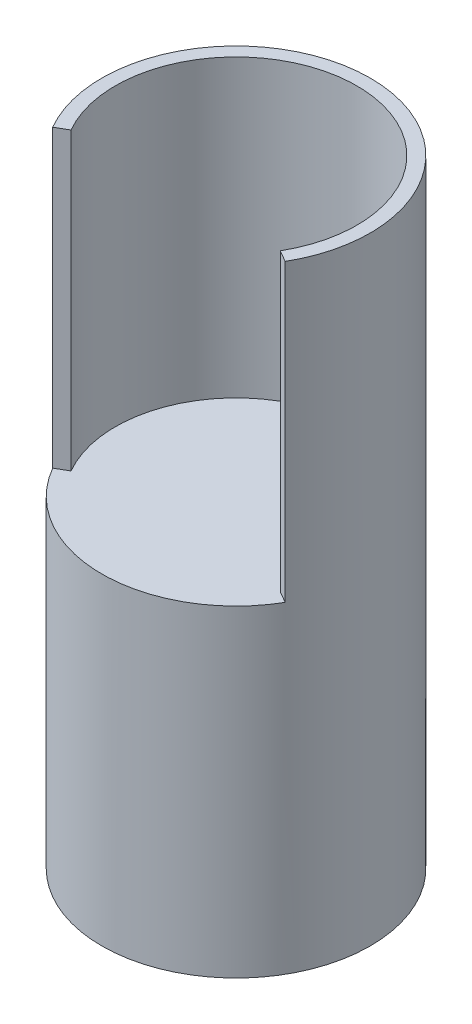
from build123d import *

# Parameters (mm, degrees)
SKETCH1_R           = 63.5
BOSS_EXTRUDE1_DEPTH = 152.4
BOSS_EXTRUDE2_DEPTH = 139.7


with BuildPart() as part:
    # Sketch1 → Boss-Extrude1 (new body)
    with BuildSketch(Plane(origin=(0, 0, 0), x_dir=(1, 0, 0), z_dir=(0, 1, 0))):
        Circle(SKETCH1_R)
    extrude(amount=BOSS_EXTRUDE1_DEPTH)

    # Sketch3 → Boss-Extrude2 (add)
    with BuildSketch(Plane(origin=(0, 152.4, 0), x_dir=(1, 0, 0), z_dir=(0, 1, 0))):
        with BuildLine():
            Line((-54.99261314, -31.75), (-49.493351826, -28.575))
            ThreePointArc((-49.493351826, -28.575), (0, 57.15), (49.493351826, -28.575))
            Line((49.493351826, -28.575), (54.99261314, -31.75))
            ThreePointArc((54.99261314, -31.75), (0, 63.5), (-54.99261314, -31.75))
        make_face()
    extrude(amount=BOSS_EXTRUDE2_DEPTH)


solid = part.part
